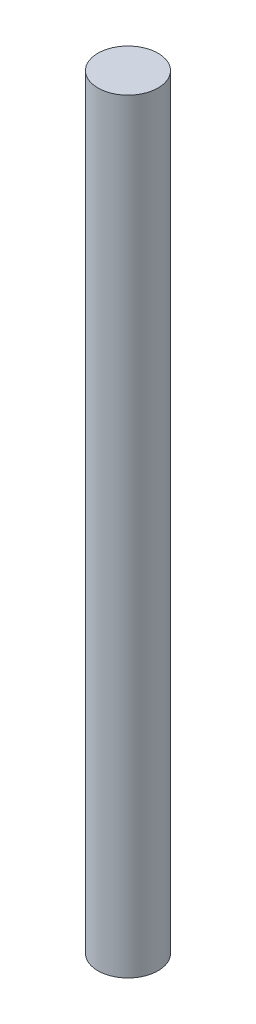
from build123d import *

# Parameters (mm, degrees)
SKETCH2_R           = 1.5
BOSS_EXTRUDE1_DEPTH = 38.1


with BuildPart() as part:
    # Sketch2 → Boss-Extrude1 (new body)
    with BuildSketch(Plane(origin=(0, 0, 0), x_dir=(1, 0, 0), z_dir=(0, 1, 0))):
        Circle(SKETCH2_R)
    extrude(amount=BOSS_EXTRUDE1_DEPTH)


solid = part.part
